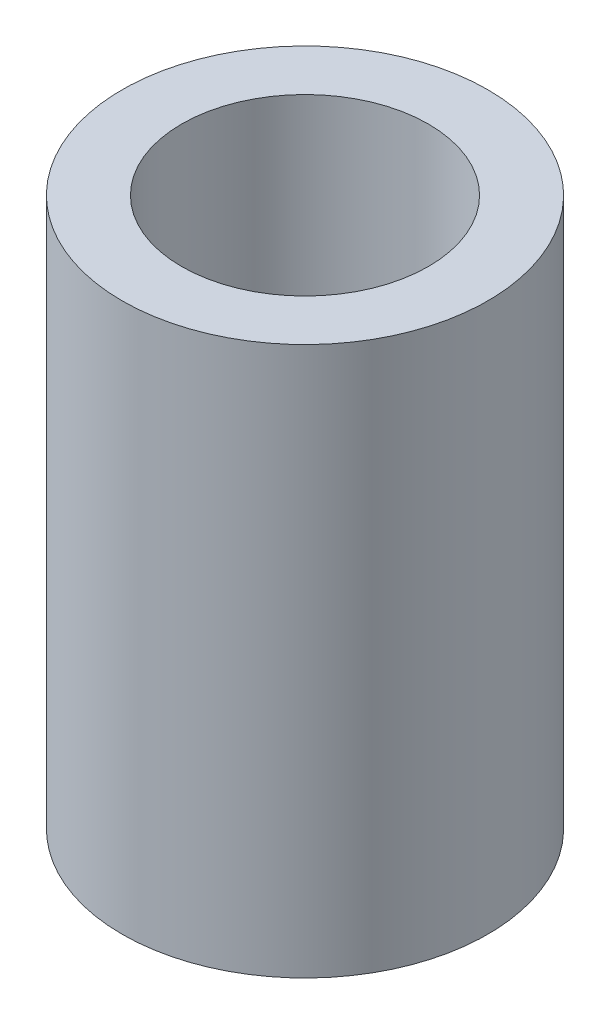
from build123d import *

# Parameters (mm, degrees)
SKETCH1_R           = 5
BOSS_EXTRUDE2_DEPTH = 15
SKETCH2_R           = 3.375
CUT_EXTRUDE1_DEPTH  = 16


with BuildPart() as part:
    # Sketch1 → Boss-Extrude2 (new body)
    with BuildSketch(Plane(origin=(0, 0, 0), x_dir=(1, 0, 0), z_dir=(0, 1, 0))):
        Circle(SKETCH1_R)
    extrude(amount=BOSS_EXTRUDE2_DEPTH)

    # Sketch2 → Cut-Extrude1 (cut, through all)
    with BuildSketch(Plane(origin=(0, 0, 0), x_dir=(1, 0, 0), z_dir=(0, 1, 0))):
        Circle(SKETCH2_R)
    extrude(amount=CUT_EXTRUDE1_DEPTH, mode=Mode.SUBTRACT)


solid = part.part
